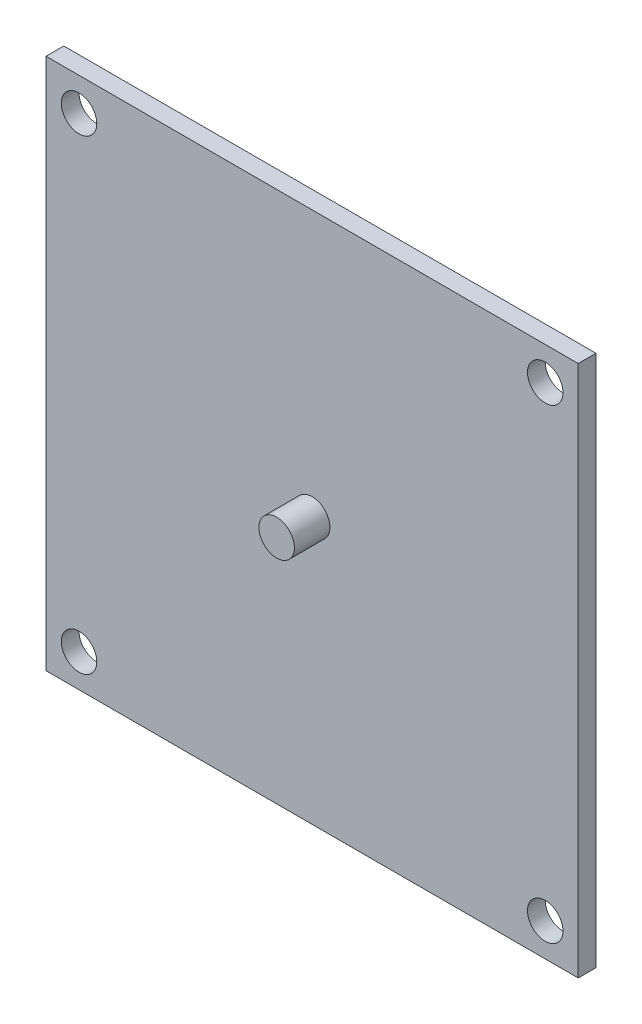
from build123d import *

# Parameters (mm, degrees)
SKETCH1_W           = 30
SKETCH1_H           = 30
BOSS_EXTRUDE1_DEPTH = 1
SKETCH2_R           = 1
CUT_EXTRUDE1_DEPTH  = 2
SKETCH3_R           = 1
BOSS_EXTRUDE2_DEPTH = 2


with BuildPart() as part:
    # Sketch1 → Boss-Extrude1 (new body)
    with BuildSketch(Plane.XY):
        Rectangle(SKETCH1_W, SKETCH1_H)
    extrude(amount=BOSS_EXTRUDE1_DEPTH)

    # Sketch2 → Cut-Extrude1 (cut, through all)
    with BuildSketch(Plane.XY.offset(1)):
        with Locations((-13.14, 13.14)):
            Circle(SKETCH2_R)
        with Locations((13.14, 13.14)):
            Circle(SKETCH2_R)
        with Locations((13.14, -13.14)):
            Circle(SKETCH2_R)
        with Locations((-13.14, -13.14)):
            Circle(SKETCH2_R)
    extrude(amount=-CUT_EXTRUDE1_DEPTH, mode=Mode.SUBTRACT)

    # Sketch3 → Boss-Extrude2 (add)
    with BuildSketch(Plane.XY.offset(1)):
        Circle(SKETCH3_R)
    extrude(amount=BOSS_EXTRUDE2_DEPTH)


solid = part.part
